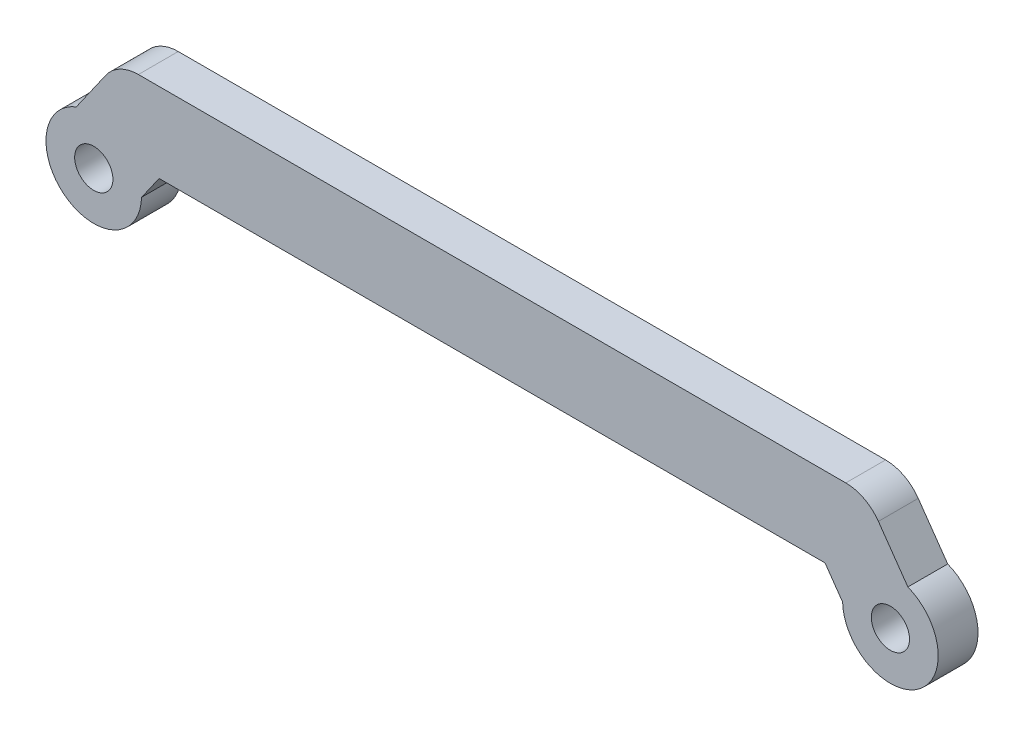
from build123d import *

# Parameters (mm, degrees)
SKETCH1_R           = 1.2
BOSS_EXTRUDE1_DEPTH = 1.25
SKETCH2_R           = 3
SKETCH2_R_2         = 1.2
BOSS_EXTRUDE2_DEPTH = 2.5


with BuildPart() as part:
    # Sketch1 → Boss-Extrude1 (new body, symmetric)
    with BuildSketch(Plane.XY):
        with BuildLine():
            Line((-20.897752221, 1.5), (20.897752221, 1.5))
            Line((20.897752221, 1.5), (22.952119889, -1.433941091))
            ThreePointArc((22.952119889, -1.433941091), (26.433941091, -2.047880111), (27.047880111, 1.433941091))
            Line((27.047880111, 1.433941091), (24.247049958, 5.433941091))
            ThreePointArc((24.247049958, 5.433941091), (23.35354138, 6.217527083), (22.199169847, 6.5))
            Line((22.199169847, 6.5), (-22.199169847, 6.5))
            ThreePointArc((-22.199169847, 6.5), (-23.35354138, 6.217527083), (-24.247049958, 5.433941091))
            Line((-24.247049958, 5.433941091), (-27.047880111, 1.433941091))
            ThreePointArc((-27.047880111, 1.433941091), (-26.433941091, -2.047880111), (-22.952119889, -1.433941091))
            Line((-22.952119889, -1.433941091), (-20.897752221, 1.5))
        make_face()
        with Locations((-25, 0)):
            Circle(SKETCH1_R, mode=Mode.SUBTRACT)
        with Locations((25, 0)):
            Circle(SKETCH1_R, mode=Mode.SUBTRACT)
    extrude(amount=BOSS_EXTRUDE1_DEPTH, both=True)

    # Sketch2 → Boss-Extrude2 (add)
    with BuildSketch(Plane(origin=(0, 0, -1.25), x_dir=(-1, 0, 0), z_dir=(0, 0, -1))):
        with Locations((25, 0)):
            Circle(SKETCH2_R)
        with Locations((25, 0)):
            Circle(SKETCH2_R_2, mode=Mode.SUBTRACT)
        with Locations((-25, 0)):
            Circle(SKETCH2_R)
        with Locations((-25, 0)):
            Circle(SKETCH2_R_2, mode=Mode.SUBTRACT)
    extrude(amount=-BOSS_EXTRUDE2_DEPTH)


solid = part.part
